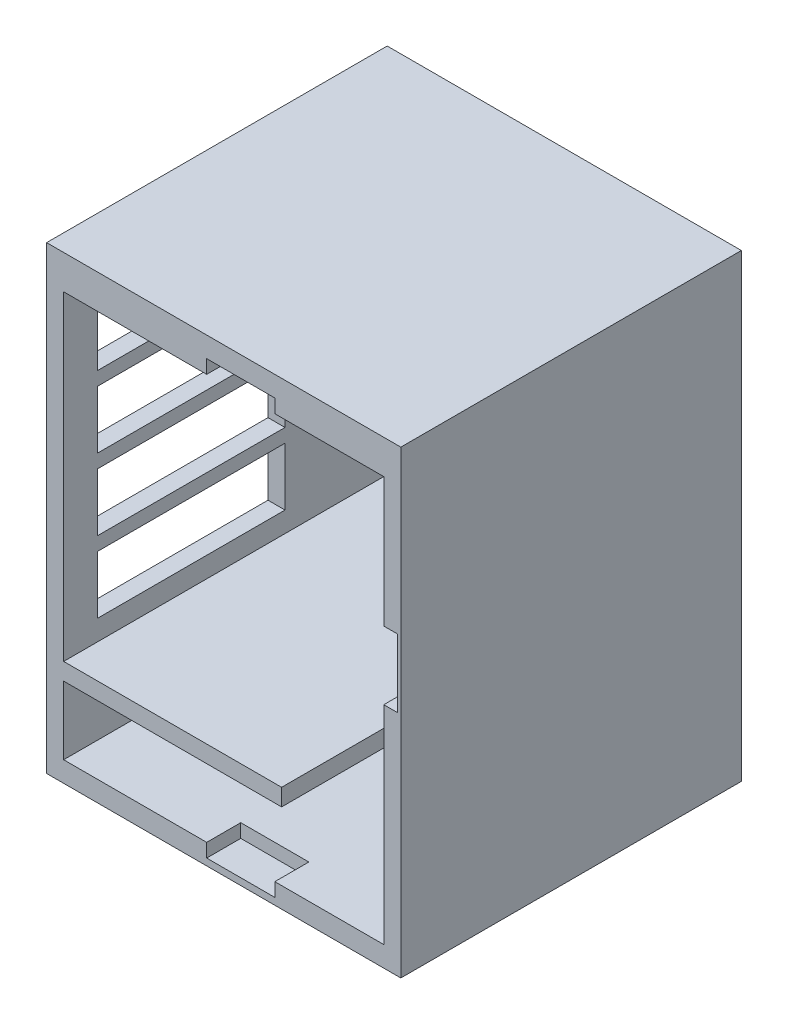
from build123d import *

# Parameters (mm, degrees)
SKETCH_1_W          = 104
SKETCH_1_H          = 135
SKETCH_1_R          = 47
EXTRUDE_2_DEPTH     = 100
SKETCH_2_W          = 94
SKETCH_2_H          = 94
CUT_EXTRUDE_1_DEPTH = 95
SKETCH_3_W          = 30
SKETCH_3_H          = 5
SKETCH_3_W_2        = 94
SKETCH_3_H_2        = 20
CUT_EXTRUDE_3_DEPTH = 70
SKETCH_4_W          = 20
SKETCH_4_H          = 4
SKETCH_4_W_2        = 4
SKETCH_4_H_2        = 20
CUT_EXTRUDE_4_DEPTH = 10
CUT_EXTRUDE_6_REACH = 106
SKETCH_6_W          = 55
SKETCH_6_H          = 17
CUT_EXTRUDE_7_REACH = 137
SKETCH_7_W          = 12
SKETCH_7_H          = 12


with BuildPart() as part:
    # 草圖1 → 填料-伸長2 (new body)
    with BuildSketch(Plane.XY):
        with Locations((-20.894077044, -18.213740458)):
            Rectangle(SKETCH_1_W, SKETCH_1_H)
        with Locations((-20.894077044, -7.713740458)):
            Circle(SKETCH_1_R, mode=Mode.SUBTRACT)
    extrude(amount=EXTRUDE_2_DEPTH)

    # 草圖2 → 除料-伸長1 (cut)
    with BuildSketch(Plane.XY.offset(100)):
        with Locations((-20.894077044, -7.713740458)):
            Rectangle(SKETCH_2_W, SKETCH_2_H)
    extrude(amount=-CUT_EXTRUDE_1_DEPTH, mode=Mode.SUBTRACT)

    # 草圖3 → 除料-伸長3 (cut)
    with BuildSketch(Plane.XY.offset(100)):
        with Locations((11.105922956, -57.213740458)):
            Rectangle(SKETCH_3_W, SKETCH_3_H)
        with Locations((-20.894077044, -69.713740458)):
            Rectangle(SKETCH_3_W_2, SKETCH_3_H_2)
    extrude(amount=-CUT_EXTRUDE_3_DEPTH, mode=Mode.SUBTRACT)

    # 草圖4 → 除料-伸長4 (cut)
    with BuildSketch(Plane.XY.offset(100)):
        with Locations((-15.894077044, -81.713740458)):
            Rectangle(SKETCH_4_W, SKETCH_4_H)
        with Locations((28.105922956, -8.713740458)):
            Rectangle(SKETCH_4_W_2, SKETCH_4_H_2)
        with Locations((-15.894077044, 41.286259542)):
            Rectangle(SKETCH_4_W, SKETCH_4_H)
    extrude(amount=-CUT_EXTRUDE_4_DEPTH, mode=Mode.SUBTRACT)

    # 草圖6 → 除料-伸長6 (cut, up to next)
    with BuildSketch(Plane.ZY.offset(72.894077044), mode=Mode.PRIVATE) as cut_extrude_6_sk1:
        with Locations((62.5, 22.786259542)):
            Rectangle(SKETCH_6_W, SKETCH_6_H)
    cut_extrude_6_tool1 = extrude(cut_extrude_6_sk1.sketch, amount=-CUT_EXTRUDE_6_REACH, mode=Mode.PRIVATE) & part.part
    add(cut_extrude_6_tool1.solids().sort_by_distance((-72.894077, 22.78626, 62.5))[0], mode=Mode.SUBTRACT)
    # 草圖6 → 除料-伸長6 (cut, up to next)
    with BuildSketch(Plane.ZY.offset(72.894077044), mode=Mode.PRIVATE) as cut_extrude_6_sk2:
        with Locations((62.5, 1.786259542)):
            Rectangle(SKETCH_6_W, SKETCH_6_H)
    cut_extrude_6_tool2 = extrude(cut_extrude_6_sk2.sketch, amount=-CUT_EXTRUDE_6_REACH, mode=Mode.PRIVATE) & part.part
    add(cut_extrude_6_tool2.solids().sort_by_distance((-72.894077, 1.78626, 62.5))[0], mode=Mode.SUBTRACT)
    # 草圖6 → 除料-伸長6 (cut, up to next)
    with BuildSketch(Plane.ZY.offset(72.894077044), mode=Mode.PRIVATE) as cut_extrude_6_sk3:
        with Locations((62.5, -19.213740458)):
            Rectangle(SKETCH_6_W, SKETCH_6_H)
    cut_extrude_6_tool3 = extrude(cut_extrude_6_sk3.sketch, amount=-CUT_EXTRUDE_6_REACH, mode=Mode.PRIVATE) & part.part
    add(cut_extrude_6_tool3.solids().sort_by_distance((-72.894077, -19.21374, 62.5))[0], mode=Mode.SUBTRACT)
    # 草圖6 → 除料-伸長6 (cut, up to next)
    with BuildSketch(Plane.ZY.offset(72.894077044), mode=Mode.PRIVATE) as cut_extrude_6_sk4:
        with Locations((62.5, -40.213740458)):
            Rectangle(SKETCH_6_W, SKETCH_6_H)
    cut_extrude_6_tool4 = extrude(cut_extrude_6_sk4.sketch, amount=-CUT_EXTRUDE_6_REACH, mode=Mode.PRIVATE) & part.part
    add(cut_extrude_6_tool4.solids().sort_by_distance((-72.894077, -40.21374, 62.5))[0], mode=Mode.SUBTRACT)

    # 草圖7 → 除料-伸長7 (cut, up to next)
    with BuildSketch(Plane.XZ.offset(85.713740458), mode=Mode.PRIVATE) as cut_extrude_7_sk1:
        with Locations((5.105922956, 49)):
            Rectangle(SKETCH_7_W, SKETCH_7_H)
    cut_extrude_7_tool1 = extrude(cut_extrude_7_sk1.sketch, amount=-CUT_EXTRUDE_7_REACH, mode=Mode.PRIVATE) & part.part
    add(cut_extrude_7_tool1.solids().sort_by_distance((5.105923, -85.71374, 49))[0], mode=Mode.SUBTRACT)
    # 草圖7 → 除料-伸長7 (cut, up to next)
    with BuildSketch(Plane.XZ.offset(85.713740458), mode=Mode.PRIVATE) as cut_extrude_7_sk2:
        with Locations((-46.894077044, 49)):
            Rectangle(SKETCH_7_W, SKETCH_7_H)
    cut_extrude_7_tool2 = extrude(cut_extrude_7_sk2.sketch, amount=-CUT_EXTRUDE_7_REACH, mode=Mode.PRIVATE) & part.part
    add(cut_extrude_7_tool2.solids().sort_by_distance((-46.894077, -85.71374, 49))[0], mode=Mode.SUBTRACT)


solid = part.part
